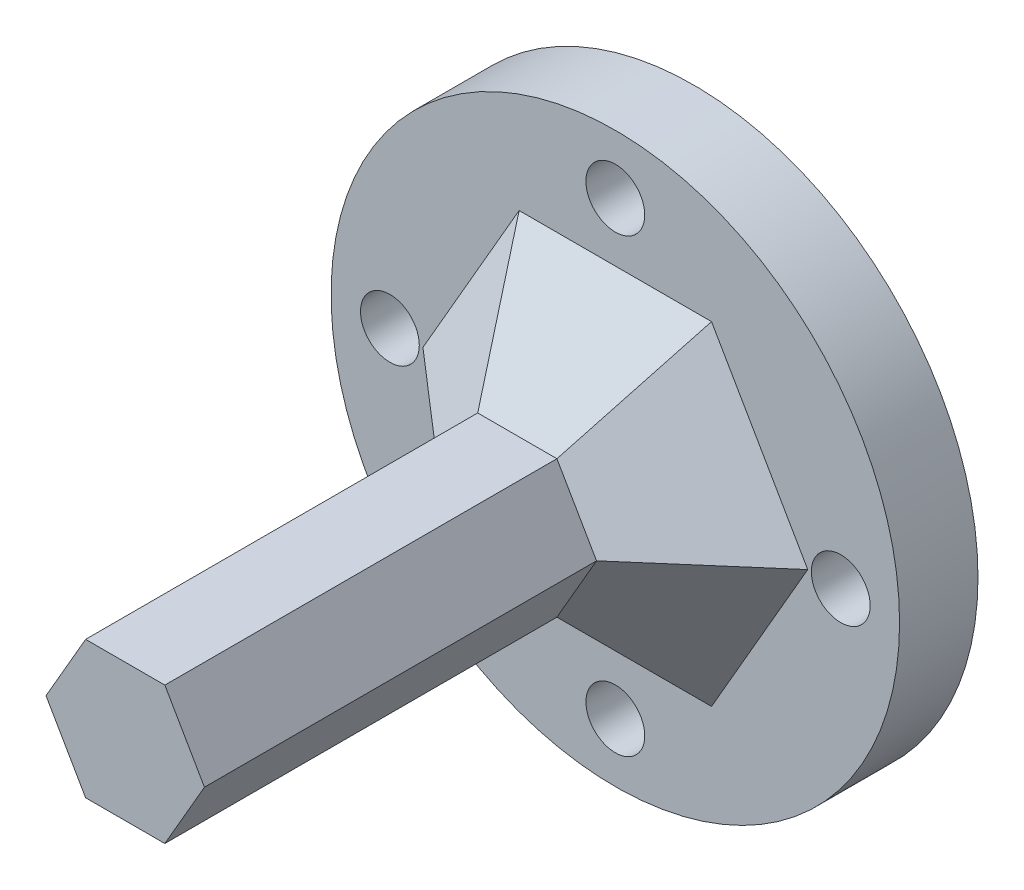
from build123d import *

# Parameters (mm, degrees)
SKETCH1_R           = 14.5
SKETCH1_R_2         = 1.5
BOSS_EXTRUDE1_DEPTH = 4
BOSS_EXTRUDE2_DEPTH = 25
CHAMFER1_SIZE       = 5


with BuildPart() as part:
    # Sketch1 → Boss-Extrude1 (new body)
    with BuildSketch(Plane.XY):
        with Locations((43.483141232, -69.989052064)):
            Circle(SKETCH1_R)
        with Locations((43.483141232, -58.489052064)):
            Circle(SKETCH1_R_2, mode=Mode.SUBTRACT)
        with Locations((54.983141232, -69.989052064)):
            Circle(SKETCH1_R_2, mode=Mode.SUBTRACT)
        with Locations((31.983141232, -69.989052064)):
            Circle(SKETCH1_R_2, mode=Mode.SUBTRACT)
        with Locations((43.483141232, -81.489052064)):
            Circle(SKETCH1_R_2, mode=Mode.SUBTRACT)
    extrude(amount=BOSS_EXTRUDE1_DEPTH)

    # Sketch2 → Boss-Extrude2 (add)
    with BuildSketch(Plane.XY.offset(4)):
        Polygon((47.524593117, -69.989052064), (45.503867174, -66.489052064), (41.46241529, -66.489052064), (39.441689348, -69.989052064), (41.46241529, -73.489052064), (45.503867174, -73.489052064), align=None)
    extrude(amount=BOSS_EXTRUDE2_DEPTH)

    # Chamfer1
    chamfer1_edges = [part.edges().sort_by_distance(p)[0] for p in [
        (46.514230145, -71.739052064, 4),
        (46.514230145, -68.239052064, 4),
        (43.483141232, -66.489052064, 4),
        (40.452052319, -68.239052064, 4),
        (40.452052319, -71.739052064, 4),
        (43.483141232, -73.489052064, 4),
    ]]
    chamfer(chamfer1_edges, length=CHAMFER1_SIZE)


solid = part.part
